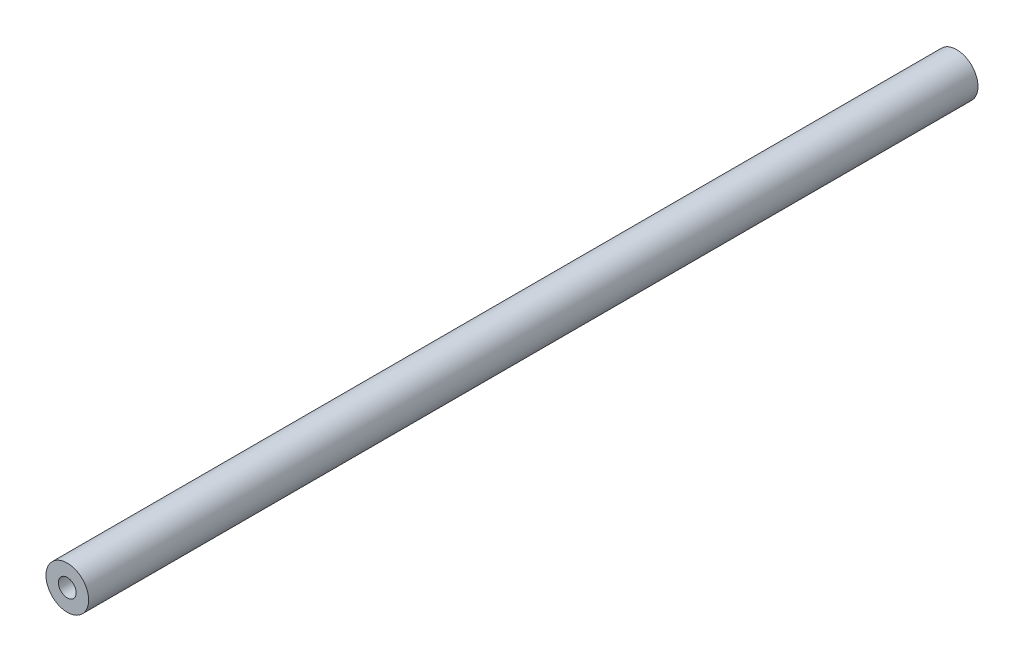
from build123d import *

# Parameters (mm, degrees)
CROQUIS1_R              = 6
SALIENTE_EXTRUIR1_DEPTH = 250
CROQUIS2_R              = 2.5
CORTAR_EXTRUIR1_DEPTH   = 15
CROQUIS3_R              = 2.5
CORTAR_EXTRUIR2_DEPTH   = 15


with BuildPart() as part:
    # Croquis1 → Saliente-Extruir1 (new body)
    with BuildSketch(Plane.XY):
        Circle(CROQUIS1_R)
    extrude(amount=SALIENTE_EXTRUIR1_DEPTH)

    # Croquis2 → Cortar-Extruir1 (cut)
    with BuildSketch(Plane.XY.offset(250)):
        Circle(CROQUIS2_R)
    extrude(amount=-CORTAR_EXTRUIR1_DEPTH, mode=Mode.SUBTRACT)

    # Croquis3 → Cortar-Extruir2 (cut)
    with BuildSketch(Plane(origin=(0, 0, 0), x_dir=(-1, 0, 0), z_dir=(0, 0, -1))):
        Circle(CROQUIS3_R)
    extrude(amount=-CORTAR_EXTRUIR2_DEPTH, mode=Mode.SUBTRACT)


solid = part.part
